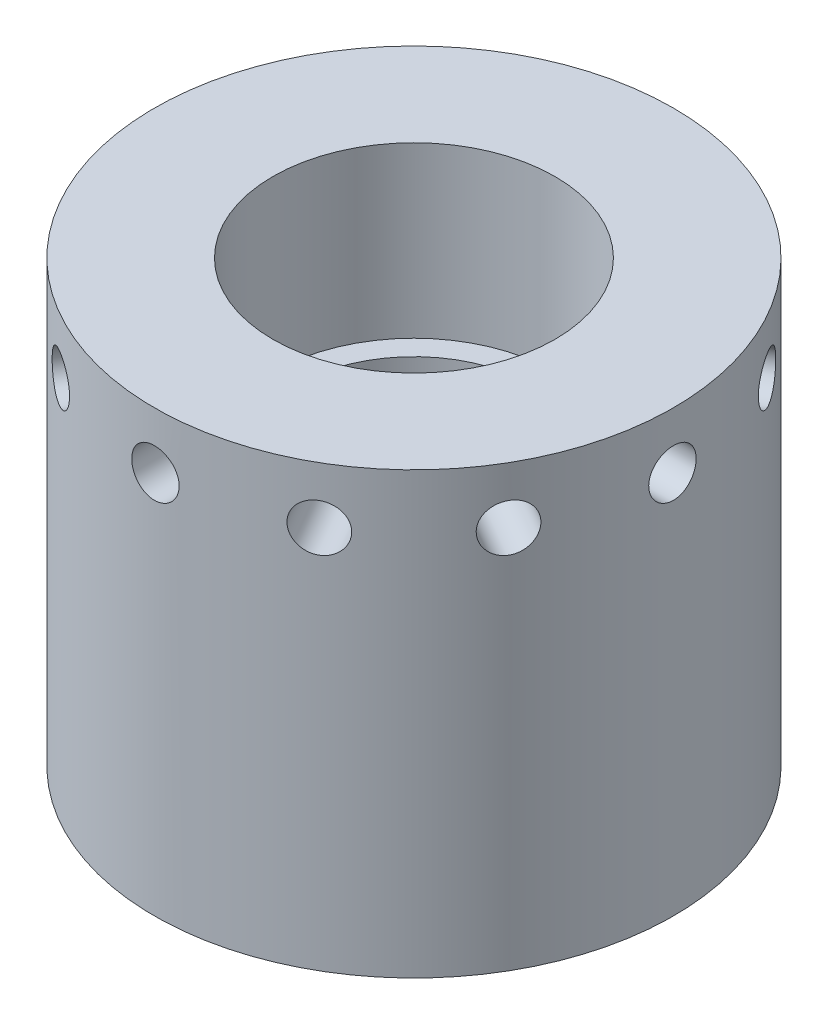
from build123d import *

# Parameters (mm, degrees)
CIRPATTERN4_COUNT = 6
CIRPATTERN3_COUNT = 12


with BuildPart() as part:
    # Sketch1 → Revolve1 (revolve)
    with BuildSketch(Plane.XY):
        Polygon((12.5, 39), (23, 39), (23, 0), (10.5, 0), (10.5, 24), (12.5, 24), align=None)
    revolve(axis=Axis((0, 64.150553744, 0), (0, 1, 0)))

    # Sketch2 → Cut-Revolve1 (revolve, cut)
    with BuildSketch(Plane.XY):
        Polygon((15, 21), (1, 21), (1, 17), (1, 0), (17, 0), (17, 17), (15, 17), align=None)
    revolve(axis=Axis((1, 17, 0), (0, -1, 0)), mode=Mode.SUBTRACT)

    # Sketch17 → M4x0.7 Tapped Hole1 (revolve, cut)
    with BuildSketch(Plane(origin=(1, 0, 18.5), x_dir=(0, 0, -1), z_dir=(1, 0, 0))):
        Polygon((0, 0), (0, 11.091420021), (1.65, 10.1), (1.65, 0), align=None)
    m4x0_7_tapped_hole1 = revolve(axis=Axis((1, -6.35, 18.5), (0, 1, 0)), mode=Mode.SUBTRACT)

    # CirPattern4: M4x0.7 Tapped Hole1 ×6 about axis
    cirpattern4_axis = Axis((1, 0, 0), (0, 1, 0))
    for i in range(1, CIRPATTERN4_COUNT):
        add(m4x0_7_tapped_hole1.rotate(cirpattern4_axis, i * 360 / CIRPATTERN4_COUNT), mode=Mode.SUBTRACT)

    # Sketch14 → M5x0.8 Tapped Hole1 (revolve, cut)
    with BuildSketch(Plane(origin=(-23, 34, 0), x_dir=(0, 0, 1), z_dir=(0, 1, 0))):
        Polygon((0, 0), (0, 9.2618073), (2.1, 8), (2.1, 0), align=None)
    m5x0_8_tapped_hole1 = revolve(axis=Axis((-29.35, 34, 0), (1, 0, 0)), mode=Mode.SUBTRACT)

    # CirPattern3: M5x0.8 Tapped Hole1 ×12 about axis
    cirpattern3_axis = Axis((0, 64.150553744, 0), (0, -1, 0))
    for i in range(1, CIRPATTERN3_COUNT):
        add(m5x0_8_tapped_hole1.rotate(cirpattern3_axis, i * 360 / CIRPATTERN3_COUNT), mode=Mode.SUBTRACT)


solid = part.part
